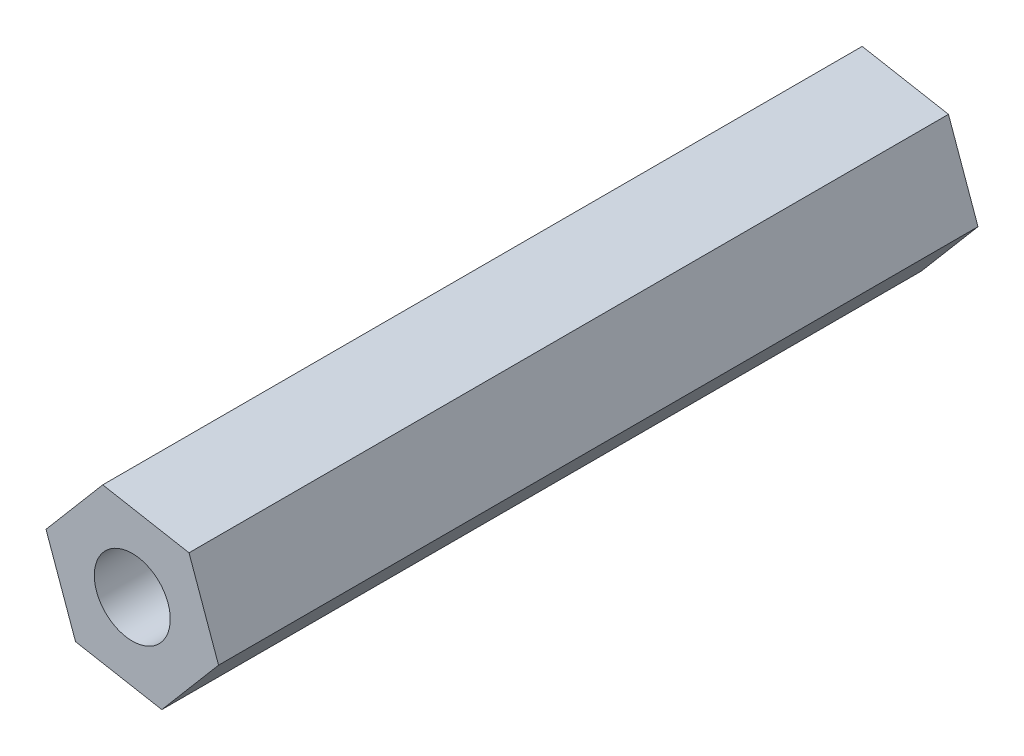
from build123d import *

# Parameters (mm, degrees)
RESSALTO_EXTRUS_O1_DEPTH = 30
ESBO_O4_R                = 1.5
CORTE_EXTRUS_O2_DEPTH    = 40


with BuildPart() as part:
    # Esboço1 → Ressalto-extrusão1 (new body)
    with BuildSketch(Plane.XY):
        Polygon((12.933175524, -4.143885809), (9.525050306, -3.523658029), (7.283854683, -6.165067156), (8.450784277, -9.426704064), (11.858909495, -10.046931845), (14.100105118, -7.405522718), align=None)
    extrude(amount=RESSALTO_EXTRUS_O1_DEPTH)

    # Esboço4 → Corte-extrusão2 (cut)
    with BuildSketch(Plane(origin=(0, 0, 0), x_dir=(-1, 0, 0), z_dir=(0, 0, -1))):
        with Locations((-10.691979901, -6.785294937)):
            Circle(ESBO_O4_R)
    extrude(amount=-CORTE_EXTRUS_O2_DEPTH, mode=Mode.SUBTRACT)


solid = part.part
